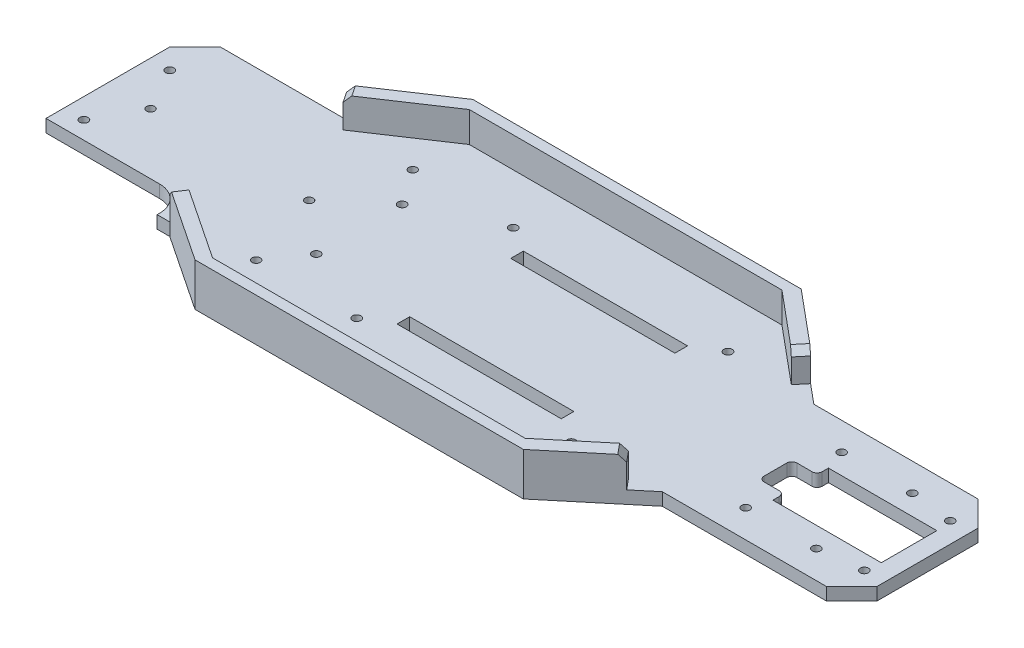
from build123d import *

# Parameters (mm, degrees)
BOSS_EXTRUDE1_DEPTH      = 5
CHASSIS_WALLS1_DEPTH     = 12
CHAMFER1_SIZE            = 10
CHAMFER2_SIZE            = 10
CHAMFER3_SIZE            = 2.5
SKETCH4_R                = 1.65
CUT_EXTRUDE1_DEPTH       = 10
SKETCH5_W                = 55
SKETCH5_H                = 11
CUT_EXTRUDE2_DEPTH       = 10
SKETCH6_W                = 65
SKETCH6_H                = 5
CUT_EXTRUDE3_DEPTH       = 6
FILLET1_R                = 10
SKETCH7_W                = 42.9
SKETCH7_H                = 22
CUT_EXTRUDE4_DEPTH       = 6
SKETCH9_R                = 1.625
CUT_EXTRUDE5_DEPTH       = 6
SKETCH10_W               = 10
SKETCH10_H               = 13
SERVO_CABLE_CUTOUT_DEPTH = 10
FILLET2_R                = 2
SKETCH11_R               = 1.6
CUT_EXTRUDE6_DEPTH       = 6


with BuildPart() as part:
    # Sketch1 → Boss-Extrude1 (new body)
    with BuildSketch(Plane(origin=(0, 0, 0), x_dir=(1, 0, 0), z_dir=(0, 1, 0))):
        Polygon((-95, 35), (-65, 55), (65, 55), (95, 30), (170, 30), (170, -30), (95, -30), (65, -55), (-65, -55), (-95, -35), (-155, -35), (-155, 35), align=None)
    extrude(amount=BOSS_EXTRUDE1_DEPTH)

    # Sketch3 → Chassis-Walls1 (add)
    with BuildSketch(Plane(origin=(0, 5, 0), x_dir=(1, 0, 0), z_dir=(0, 1, 0))):
        Polygon((0, 55), (-65, 55), (-95, 35), (-92.226499019, 30.839748528), (-62.226499019, 50.839748528), (0, 50.839748528), (61.533123774, 50.839748528), (83.850910978, 32.241592525), (87.317787204, 36.401843997), (65, 55), align=None)
        Polygon((61.533123774, -50.839748528), (0, -50.839748528), (-62.226499019, -50.839748528), (-92.226499019, -30.839748528), (-95, -35), (-65, -55), (0, -55), (65, -55), (87.317787204, -36.401843997), (83.850910978, -32.241592525), align=None)
    extrude(amount=CHASSIS_WALLS1_DEPTH)

    # Chamfer1
    chamfer1_edges = [part.edges().sort_by_distance(p)[0] for p in [
        (-155, 2.5, 35),
        (-155, 2.5, -35),
    ]]
    chamfer(chamfer1_edges, length=CHAMFER1_SIZE)

    # Chamfer2
    chamfer2_edges = [part.edges().sort_by_distance(p)[0] for p in [
        (170, 2.5, -30),
        (170, 2.5, 30),
    ]]
    chamfer(chamfer2_edges, length=CHAMFER2_SIZE)

    # Chamfer3
    chamfer3_edges = [part.edges().sort_by_distance(p)[0] for p in [
        (-93.613249509, 17, -32.919874264),
        (85.584349091, 17, -34.321718261),
        (-93.613249509, 17, 32.919874264),
        (85.584349091, 17, 34.321718261),
    ]]
    chamfer(chamfer3_edges, length=CHAMFER3_SIZE)

    # Sketch4 → Cut-Extrude1 (cut)
    with BuildSketch(Plane.XZ):
        with Locations((-147, 17)):
            Circle(SKETCH4_R)
        with Locations((-55, 17)):
            Circle(SKETCH4_R)
        with Locations((-55, -17)):
            Circle(SKETCH4_R)
        with Locations((-147, -17)):
            Circle(SKETCH4_R)
        with Locations((-25, 31)):
            Circle(SKETCH4_R)
        with Locations((60, 31)):
            Circle(SKETCH4_R)
        with Locations((60, -31)):
            Circle(SKETCH4_R)
        with Locations((-25, -31)):
            Circle(SKETCH4_R)
    extrude(amount=-CUT_EXTRUDE1_DEPTH, mode=Mode.SUBTRACT)

    # Sketch5 → Cut-Extrude2 (cut)
    with BuildSketch(Plane(origin=(0, 5, 0), x_dir=(1, 0, 0), z_dir=(0, 1, 0))):
        with Locations((-127.5, -29.5)):
            Rectangle(SKETCH5_W, SKETCH5_H)
    extrude(amount=-CUT_EXTRUDE2_DEPTH, mode=Mode.SUBTRACT)

    # Sketch6 → Cut-Extrude3 (cut, through all)
    with BuildSketch(Plane(origin=(0, 5, 0), x_dir=(1, 0, 0), z_dir=(0, 1, 0))):
        with Locations((17.5, 22.5)):
            Rectangle(SKETCH6_W, SKETCH6_H)
        with Locations((17.5, -22.5)):
            Rectangle(SKETCH6_W, SKETCH6_H)
    extrude(amount=-CUT_EXTRUDE3_DEPTH, mode=Mode.SUBTRACT)

    # Fillet1
    fillet1_edges = [part.edges().sort_by_distance(p)[0] for p in [
        (-100, 2.5, 24),
    ]]
    fillet(fillet1_edges, radius=FILLET1_R)

    # Sketch7 → Cut-Extrude4 (cut, through all)
    with BuildSketch(Plane(origin=(0, 5, 0), x_dir=(1, 0, 0), z_dir=(0, 1, 0))):
        with Locations((141.25, 0)):
            Rectangle(SKETCH7_W, SKETCH7_H)
    extrude(amount=-CUT_EXTRUDE4_DEPTH, mode=Mode.SUBTRACT)

    # Sketch9 → Cut-Extrude5 (cut, through all)
    with BuildSketch(Plane(origin=(0, 5, 0), x_dir=(1, 0, 0), z_dir=(0, 1, 0))):
        with Locations((117, -19)):
            Circle(SKETCH9_R)
        with Locations((145, -19)):
            Circle(SKETCH9_R)
        with Locations((162, -17)):
            Circle(SKETCH9_R)
    cut_extrude5 = extrude(amount=-CUT_EXTRUDE5_DEPTH, mode=Mode.SUBTRACT)

    # Mirror1: Cut-Extrude5 across plane
    add(cut_extrude5.mirror(Plane.XY), mode=Mode.SUBTRACT)

    # Sketch10 → Servo-Cable-Cutout (cut)
    with BuildSketch(Plane(origin=(0, 5, 0), x_dir=(1, 0, 0), z_dir=(0, 1, 0))):
        with Locations((114.8, 0)):
            Rectangle(SKETCH10_W, SKETCH10_H)
    extrude(amount=-SERVO_CABLE_CUTOUT_DEPTH, mode=Mode.SUBTRACT)

    # Fillet2
    fillet2_edges = [part.edges().sort_by_distance(p)[0] for p in [
        (119.8, 2.5, -6.5),
        (119.8, 2.5, 6.5),
        (109.8, 2.5, 6.5),
        (109.8, 2.5, -6.5),
    ]]
    fillet(fillet2_edges, radius=FILLET2_R)

    # Sketch11 → Cut-Extrude6 (cut, through all)
    with BuildSketch(Plane(origin=(0, 5, 0), x_dir=(1, 0, 0), z_dir=(0, 1, 0))):
        with Locations((-137.6, 0)):
            Circle(SKETCH11_R)
        with Locations((-74.8, 0)):
            Circle(SKETCH11_R)
        with Locations((-64.8, 31)):
            Circle(SKETCH11_R)
        with Locations((-64.8, -31)):
            Circle(SKETCH11_R)
    extrude(amount=-CUT_EXTRUDE6_DEPTH, mode=Mode.SUBTRACT)


solid = part.part
